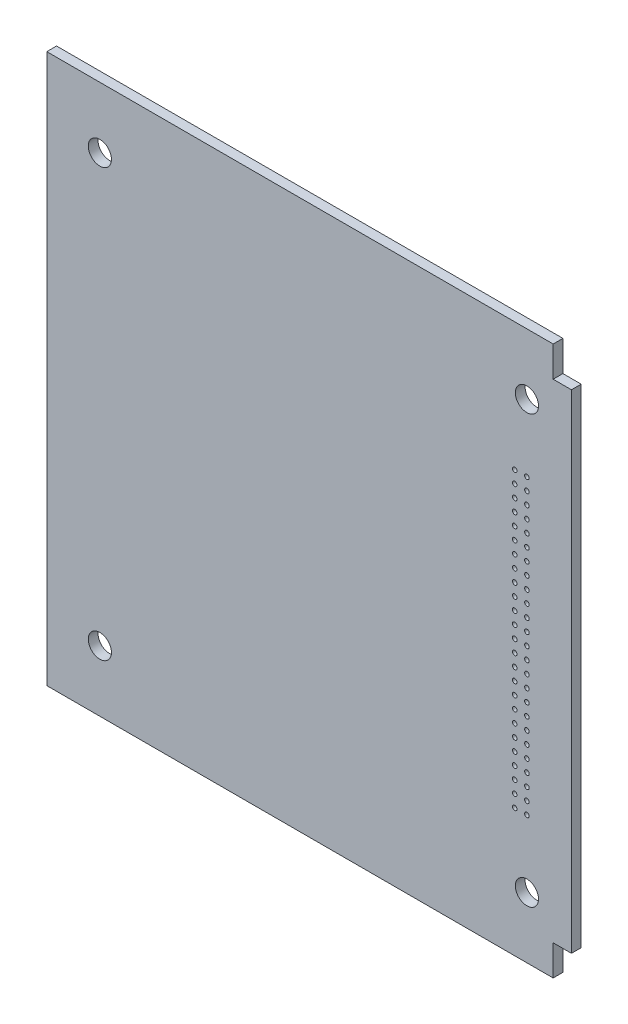
from build123d import *

# Parameters (mm, degrees)
SKETCH1_R           = 1.9
SKETCH1_R_2         = 0.375
SKETCH1_R_3         = 0.383755901
SKETCH1_R_4         = 0.384163196
SKETCH1_R_5         = 0.380771211
SKETCH1_R_6         = 0.377379225
SKETCH1_R_7         = 0.380832793
BOSS_EXTRUDE1_DEPTH = 1.6


with BuildPart() as part:
    # Sketch1 → Boss-Extrude1 (new body)
    with BuildSketch(Plane.XY):
        Polygon((-3, 0), (-86, 0), (-86, -90), (-3, -90), (-3, -85), (0, -85), (0, -5), (-3, -5), align=None)
        with Locations((-7.3, -10)):
            Circle(SKETCH1_R, mode=Mode.SUBTRACT)
        with Locations((-77.3, -10)):
            Circle(SKETCH1_R, mode=Mode.SUBTRACT)
        with Locations((-77.3, -80)):
            Circle(SKETCH1_R, mode=Mode.SUBTRACT)
        with Locations((-7.3, -80)):
            Circle(SKETCH1_R, mode=Mode.SUBTRACT)
        with Locations((-9.3, -69)):
            Circle(SKETCH1_R_2, mode=Mode.SUBTRACT)
        with Locations((-7.3, -69)):
            Circle(SKETCH1_R_2, mode=Mode.SUBTRACT)
        with Locations((-7.3, -67)):
            Circle(SKETCH1_R_2, mode=Mode.SUBTRACT)
        with Locations((-9.3, -67)):
            Circle(SKETCH1_R_2, mode=Mode.SUBTRACT)
        with Locations((-9.3, -65)):
            Circle(SKETCH1_R_2, mode=Mode.SUBTRACT)
        with Locations((-7.3, -65)):
            Circle(SKETCH1_R_2, mode=Mode.SUBTRACT)
        with Locations((-7.3, -63)):
            Circle(SKETCH1_R_2, mode=Mode.SUBTRACT)
        with Locations((-9.3, -63)):
            Circle(SKETCH1_R_3, mode=Mode.SUBTRACT)
        with Locations((-9.3, -61)):
            Circle(SKETCH1_R_2, mode=Mode.SUBTRACT)
        with Locations((-7.3, -61)):
            Circle(SKETCH1_R_2, mode=Mode.SUBTRACT)
        with Locations((-7.3, -59)):
            Circle(SKETCH1_R_2, mode=Mode.SUBTRACT)
        with Locations((-9.3, -59)):
            Circle(SKETCH1_R_2, mode=Mode.SUBTRACT)
        with Locations((-7.3, -57)):
            Circle(SKETCH1_R_2, mode=Mode.SUBTRACT)
        with Locations((-9.3, -57)):
            Circle(SKETCH1_R_2, mode=Mode.SUBTRACT)
        with Locations((-9.3, -55)):
            Circle(SKETCH1_R_2, mode=Mode.SUBTRACT)
        with Locations((-7.3, -55)):
            Circle(SKETCH1_R_2, mode=Mode.SUBTRACT)
        with Locations((-7.3, -53)):
            Circle(SKETCH1_R_2, mode=Mode.SUBTRACT)
        with Locations((-9.3, -53)):
            Circle(SKETCH1_R_2, mode=Mode.SUBTRACT)
        with Locations((-9.3, -51)):
            Circle(SKETCH1_R_2, mode=Mode.SUBTRACT)
        with Locations((-7.3, -51)):
            Circle(SKETCH1_R_2, mode=Mode.SUBTRACT)
        with Locations((-7.3, -49)):
            Circle(SKETCH1_R_2, mode=Mode.SUBTRACT)
        with Locations((-9.3, -49)):
            Circle(SKETCH1_R_2, mode=Mode.SUBTRACT)
        with Locations((-9.3, -47)):
            Circle(SKETCH1_R_2, mode=Mode.SUBTRACT)
        with Locations((-7.3, -47)):
            Circle(SKETCH1_R_2, mode=Mode.SUBTRACT)
        with Locations((-7.3, -45)):
            Circle(SKETCH1_R_2, mode=Mode.SUBTRACT)
        with Locations((-9.3, -45)):
            Circle(SKETCH1_R_4, mode=Mode.SUBTRACT)
        with Locations((-9.3, -43)):
            Circle(SKETCH1_R_2, mode=Mode.SUBTRACT)
        with Locations((-7.3, -43)):
            Circle(SKETCH1_R_5, mode=Mode.SUBTRACT)
        with Locations((-7.3, -41)):
            Circle(SKETCH1_R_6, mode=Mode.SUBTRACT)
        with Locations((-9.3, -41)):
            Circle(SKETCH1_R_6, mode=Mode.SUBTRACT)
        with Locations((-9.3, -39)):
            Circle(SKETCH1_R_2, mode=Mode.SUBTRACT)
        with Locations((-7.3, -39)):
            Circle(SKETCH1_R_2, mode=Mode.SUBTRACT)
        with Locations((-7.3, -37)):
            Circle(SKETCH1_R_2, mode=Mode.SUBTRACT)
        with Locations((-9.3, -37)):
            Circle(SKETCH1_R_7, mode=Mode.SUBTRACT)
        with Locations((-7.3, -35)):
            Circle(SKETCH1_R_2, mode=Mode.SUBTRACT)
        with Locations((-9.3, -35)):
            Circle(SKETCH1_R_2, mode=Mode.SUBTRACT)
        with Locations((-9.3, -33)):
            Circle(SKETCH1_R_2, mode=Mode.SUBTRACT)
        with Locations((-7.3, -33)):
            Circle(SKETCH1_R_2, mode=Mode.SUBTRACT)
        with Locations((-7.3, -31)):
            Circle(SKETCH1_R_2, mode=Mode.SUBTRACT)
        with Locations((-9.3, -31)):
            Circle(SKETCH1_R_2, mode=Mode.SUBTRACT)
        with Locations((-7.3, -29)):
            Circle(SKETCH1_R_2, mode=Mode.SUBTRACT)
        with Locations((-9.3, -29)):
            Circle(SKETCH1_R_2, mode=Mode.SUBTRACT)
        with Locations((-9.3, -27)):
            Circle(SKETCH1_R_2, mode=Mode.SUBTRACT)
        with Locations((-7.3, -27)):
            Circle(SKETCH1_R_2, mode=Mode.SUBTRACT)
        with Locations((-7.3, -25)):
            Circle(SKETCH1_R_2, mode=Mode.SUBTRACT)
        with Locations((-9.3, -25)):
            Circle(SKETCH1_R_2, mode=Mode.SUBTRACT)
        with Locations((-7.3, -23)):
            Circle(SKETCH1_R_2, mode=Mode.SUBTRACT)
        with Locations((-9.3, -23)):
            Circle(SKETCH1_R_2, mode=Mode.SUBTRACT)
        with Locations((-9.3, -21)):
            Circle(SKETCH1_R_2, mode=Mode.SUBTRACT)
        with Locations((-7.3, -21)):
            Circle(SKETCH1_R_2, mode=Mode.SUBTRACT)
    extrude(amount=BOSS_EXTRUDE1_DEPTH)


solid = part.part
